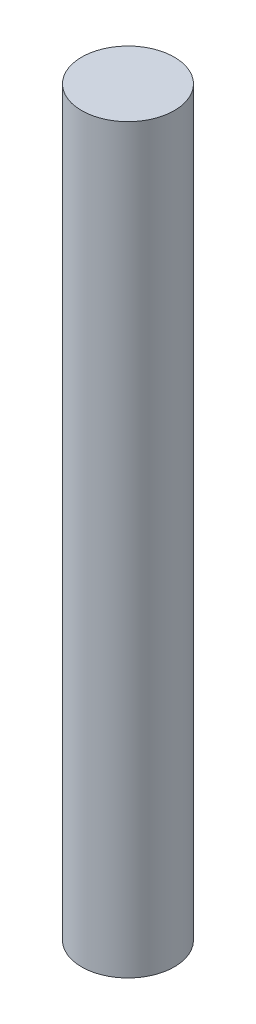
from build123d import *

# Parameters (mm, degrees)
SKETCH1_R           = 4.7625
BOSS_EXTRUDE1_DEPTH = 76.2


with BuildPart() as part:
    # Sketch1 → Boss-Extrude1 (new body)
    with BuildSketch(Plane(origin=(0, 0, 0), x_dir=(1, 0, 0), z_dir=(0, 1, 0))):
        Circle(SKETCH1_R)
    extrude(amount=BOSS_EXTRUDE1_DEPTH)


solid = part.part
